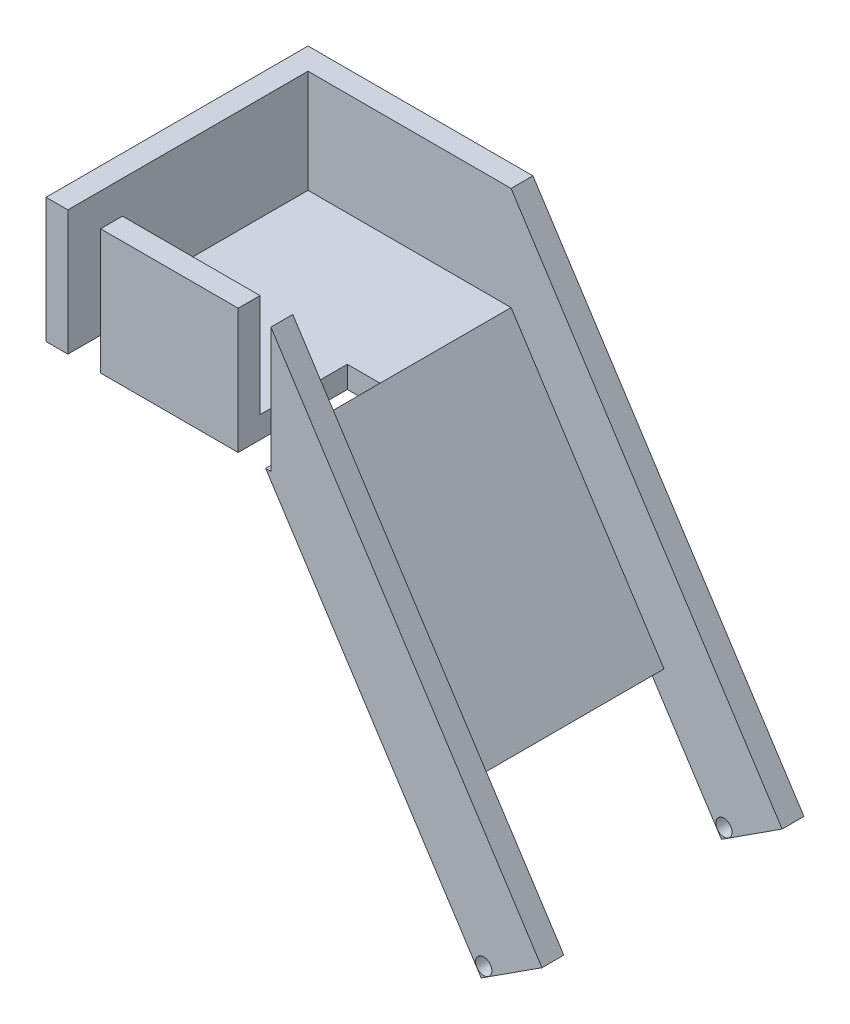
from build123d import *

# Parameters (mm, degrees)
BOSS_EXTRU_1_DEPTH                  = 120
BOSS_EXTRU_3_DEPTH                  = 47.25
BOSS_EXTRU_4_DEPTH                  = 10
BOSS_EXTRU_5_DEPTH                  = 10
ESQUISSE6_W                         = 15
ESQUISSE6_H                         = 57.25
ENL_V_MAT_EXTRU_1_DEPTH             = 50
ESQUISSE7_W                         = 100
ESQUISSE7_H                         = 60
ENL_V_MAT_EXTRU_2_DEPTH             = 10
ESQUISSE8_R                         = 3.73
ENL_V_MAT_EXTRU_3_DEPTH             = 10
ENL_V_MAT_EXTRU_3_DIRECTION_2_REACH = 112


with BuildPart() as part:
    # Esquisse1 → Boss.-Extru.1 (new body)
    with BuildSketch(Plane.XY):
        Polygon((-33.531301397, 99.715192212), (69.079300245, -59.00488979), (62.817327254, -63.053179131), (-35.94556587, 89.715192212), (-136.531301397, 89.715192212), (-136.531301397, 99.715192212), align=None)
    extrude(amount=-BOSS_EXTRU_1_DEPTH)

    # Esquisse3 → Boss.-Extru.3 (add)
    with BuildSketch(Plane(origin=(0, 99.715192212, 0), x_dir=(1, 0, 0), z_dir=(0, 1, 0))):
        Polygon((-33.531301397, 110), (-33.531301397, 120), (-136.531301397, 120), (-136.531301397, 0), (-33.531301397, 0), (-33.531301397, 10), (-126.531301397, 10), (-126.531301397, 110), align=None)
    extrude(amount=BOSS_EXTRU_3_DEPTH)

    # Esquisse4 → Boss.-Extru.4 (add)
    with BuildSketch(Plane.XY):
        Polygon((-33.531301397, 146.965192212), (90.622108587, -45.077726339), (69.079300245, -59.00488979), (-33.531301397, 99.715192212), align=None)
    extrude(amount=-BOSS_EXTRU_4_DEPTH)

    # Esquisse5 → Boss.-Extru.5 (add)
    with BuildSketch(Plane(origin=(0, 0, -120), x_dir=(-1, 0, 0), z_dir=(0, 0, -1))):
        Polygon((33.531301397, 99.715192212), (33.531301397, 146.965192212), (-90.622108587, -45.077726339), (-69.079300245, -59.00488979), align=None)
    extrude(amount=-BOSS_EXTRU_5_DEPTH)

    # Esquisse6 → Enlèv. mat.-Extru.1 (cut)
    with BuildSketch(Plane.XY):
        with Locations((-119.031301397, 118.340192212)):
            Rectangle(ESQUISSE6_W, ESQUISSE6_H)
        with Locations((-41.031301397, 118.340192212)):
            Rectangle(ESQUISSE6_W, ESQUISSE6_H)
    extrude(amount=-ENL_V_MAT_EXTRU_1_DEPTH, mode=Mode.SUBTRACT)

    # Esquisse7 → Enlèv. mat.-Extru.2 (cut)
    with BuildSketch(Plane(origin=(21.815602094, 14.103521292, 0), x_dir=(0, 0, -1), z_dir=(0.839788794, 0.542913236, 0))):
        with Locations((60, -57.055711668)):
            Rectangle(ESQUISSE7_W, ESQUISSE7_H)
    extrude(amount=-ENL_V_MAT_EXTRU_2_DEPTH, mode=Mode.SUBTRACT)

    # Esquisse8 → Enlèv. mat.-Extru.3 (cut)
    with BuildSketch(Plane.XY.offset(-110)):
        with Locations((63.942262825, -57.813776091)):
            Circle(ESQUISSE8_R)
    extrude(amount=-ENL_V_MAT_EXTRU_3_DEPTH, mode=Mode.SUBTRACT)

    # Esquisse8 → Enlèv. mat.-Extru.3 direction 2 (cut, up to next)
    with BuildSketch(Plane.XY.offset(-110), mode=Mode.PRIVATE) as enl_v_mat_extru_3_direction_2_sk1:
        with Locations((63.942262825, -57.813776091)):
            Circle(ESQUISSE8_R)
    enl_v_mat_extru_3_direction_2_tool1 = extrude(enl_v_mat_extru_3_direction_2_sk1.sketch, amount=ENL_V_MAT_EXTRU_3_DIRECTION_2_REACH, mode=Mode.PRIVATE) & part.part
    add(enl_v_mat_extru_3_direction_2_tool1.solids().sort_by_distance((63.942263, -57.813776, -110))[0], mode=Mode.SUBTRACT)


solid = part.part
